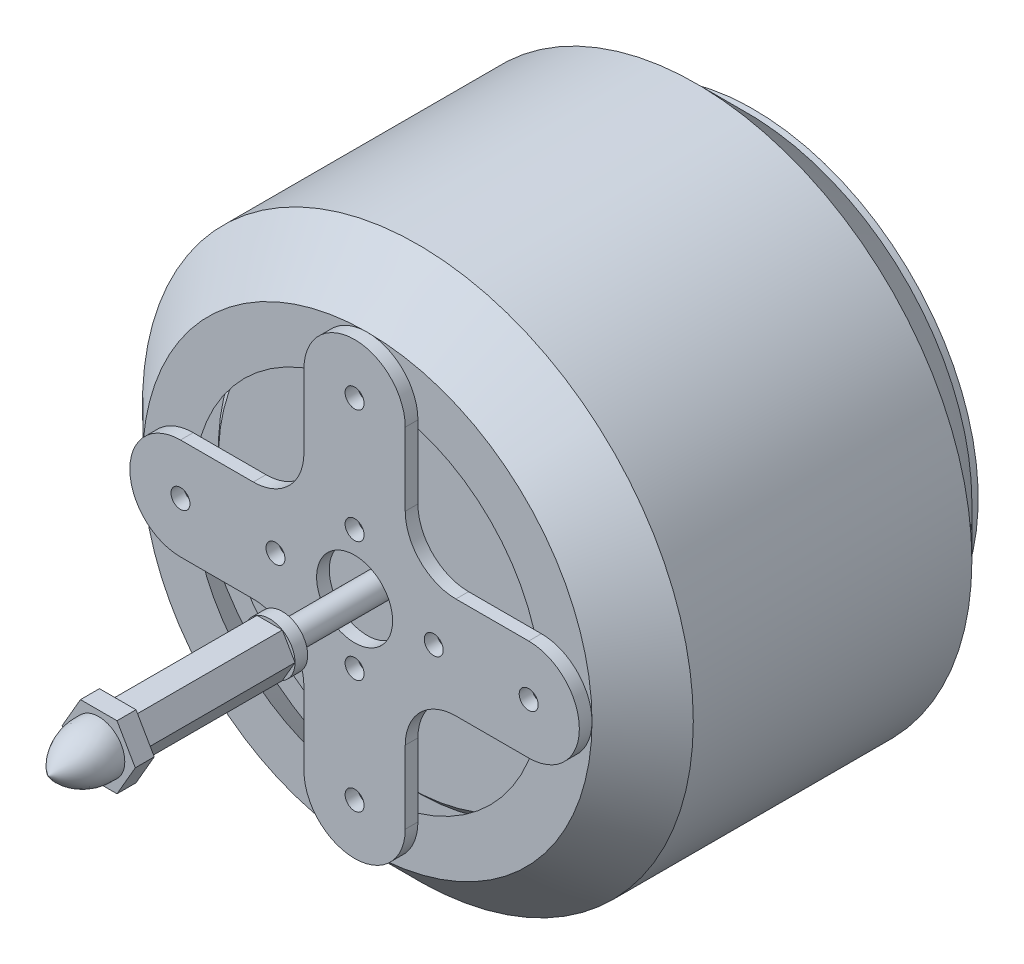
from build123d import *

# Parameters (mm, degrees)
IZIM1_R                     = 6
IZIM1_R_2                   = 1.5
Y_KSEKLIK_EKSTR_ZYON1_DEPTH = 2
RADYUS1_R                   = 8
IZIM5_R                     = 35.5
Y_KSEKLIK_EKSTR_ZYON2_DEPTH = 1
IZIM6_R                     = 2
Y_KSEKLIK_EKSTR_ZYON3_DEPTH = 20
IZIM7_R                     = 4
Y_KSEKLIK_EKSTR_ZYON4_DEPTH = 2
Y_KSEKLIK_EKSTR_ZYON5_DEPTH = 24
Y_KSEKLIK_EKSTR_ZYON6_DEPTH = 3


with BuildPart() as part:
    # Çizim1 → Yükseklik-Ekstrüzyon1 (new body)
    with BuildSketch(Plane.XY):
        with BuildLine():
            Line((8, 27.5), (8, 8))
            Line((8, 8), (27.5, 8))
            ThreePointArc((27.5, 8), (35.5, 0), (27.5, -8))
            Line((27.5, -8), (8, -8))
            Line((8, -8), (8, -27.5))
            ThreePointArc((8, -27.5), (0, -35.5), (-8, -27.5))
            Line((-8, -27.5), (-8, -8))
            Line((-8, -8), (-27.5, -8))
            ThreePointArc((-27.5, -8), (-35.5, 0), (-27.5, 8))
            Line((-27.5, 8), (-8, 8))
            Line((-8, 8), (-8, 27.5))
            ThreePointArc((-8, 27.5), (0, 35.5), (8, 27.5))
        make_face()
        Circle(IZIM1_R, mode=Mode.SUBTRACT)
        with Locations((0, 9.5)):
            Circle(IZIM1_R_2, mode=Mode.SUBTRACT)
        with Locations((0, -9.5)):
            Circle(IZIM1_R_2, mode=Mode.SUBTRACT)
        with Locations((-12.5, 0)):
            Circle(IZIM1_R_2, mode=Mode.SUBTRACT)
        with Locations((12.5, 0)):
            Circle(IZIM1_R_2, mode=Mode.SUBTRACT)
        with Locations((0, 27.5)):
            Circle(IZIM1_R_2, mode=Mode.SUBTRACT)
        with Locations((27.5, 0)):
            Circle(IZIM1_R_2, mode=Mode.SUBTRACT)
        with Locations((0, -27.5)):
            Circle(IZIM1_R_2, mode=Mode.SUBTRACT)
        with Locations((-27.5, 0)):
            Circle(IZIM1_R_2, mode=Mode.SUBTRACT)
    extrude(amount=Y_KSEKLIK_EKSTR_ZYON1_DEPTH)

    # Radyus1
    radyus1_edges = [part.edges().sort_by_distance(p)[0] for p in [
        (8, 8, 1),
        (8, -8, 1),
        (-8, -8, 1),
        (-8, 8, 1),
    ]]
    fillet(radyus1_edges, radius=RADYUS1_R)

    # Çizim4 → Döndür1 (revolve)
    with BuildSketch(Plane(origin=(0, 0, 0), x_dir=(0, 0, -1), z_dir=(1, 0, 0))):
        Polygon((0, 27.5), (0, 35.5), (8, 43.5), (52, 43.5), (60, 35.5), (60, 27.5), (52, 35.5), (52, 31.5), (53.414213562, 30.085786438), (53.414213562, 0), (6.585786438, 0), (6.585786438, 30.085786438), (8, 31.5), (8, 35.5), align=None)
    revolve(axis=Axis((0, 0, -6.585786438), (0, 0, -1)))

    # Çizim5 → Yükseklik-Ekstrüzyon2 (add)
    with BuildSketch(Plane(origin=(0, 0, -60), x_dir=(-1, 0, 0), z_dir=(0, 0, -1))):
        Circle(IZIM5_R)
    extrude(amount=Y_KSEKLIK_EKSTR_ZYON2_DEPTH)

    # Çizim6 → Yükseklik-Ekstrüzyon3 (add)
    with BuildSketch(Plane.XY.offset(-6.585786438)):
        Circle(IZIM6_R)
    extrude(amount=Y_KSEKLIK_EKSTR_ZYON3_DEPTH)

    # Çizim7 → Yükseklik-Ekstrüzyon4 (add)
    with BuildSketch(Plane.XY.offset(13.414213562)):
        Circle(IZIM7_R)
    extrude(amount=Y_KSEKLIK_EKSTR_ZYON4_DEPTH)

    # Çizim9 → Yükseklik-Ekstrüzyon5 (add)
    with BuildSketch(Plane.XY.offset(15.414213562)):
        Polygon((4, 0), (2, 3.464101615), (-2, 3.464101615), (-4, 0), (-2, -3.464101615), (2, -3.464101615), align=None)
    extrude(amount=Y_KSEKLIK_EKSTR_ZYON5_DEPTH)

    # Çizim10 → Yükseklik-Ekstrüzyon6 (add)
    with BuildSketch(Plane.XY.offset(39.414213562)):
        Polygon((5.773502692, 0), (2.886751346, 5), (-2.886751346, 5), (-5.773502692, 0), (-2.886751346, -5), (2.886751346, -5), align=None)
    extrude(amount=Y_KSEKLIK_EKSTR_ZYON6_DEPTH)

    # Çizim11 → Döndür2 (revolve)
    with BuildSketch(Plane(origin=(0, 0, 0), x_dir=(0, 0, -1), z_dir=(1, 0, 0))):
        with BuildLine():
            Line((-42.414213562, 0), (-50.414213562, 0))
            ThreePointArc((-50.414213562, 0), (-46.98644571, 3.170331375), (-42.414213562, 4.116527269))
            Line((-42.414213562, 4.116527269), (-42.414213562, 0))
        make_face()
    revolve(axis=Axis((0, 0, 42.414213562), (0, 0, 1)))


solid = part.part
